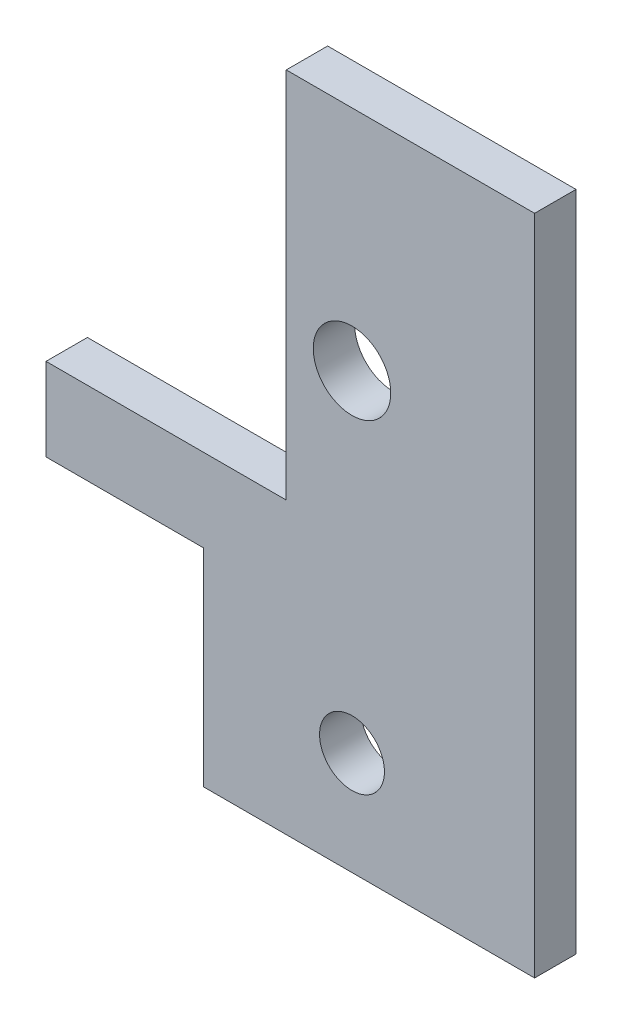
from build123d import *

# Parameters (mm, degrees)
SKETCH1_R           = 2.4892
SKETCH1_R_2         = 2.9718
BOSS_EXTRUDE1_DEPTH = 3.175
SKETCH2_W           = 18.4277
SKETCH2_H           = 6.35
CUT_EXTRUDE1_DEPTH  = 4.175


with BuildPart() as part:
    # Sketch1 → Boss-Extrude1 (new body)
    with BuildSketch(Plane.XY):
        Polygon((37.4777, 9.5377), (0, 9.5377), (0, 3.1877), (18.4277, 3.1877), (18.4277, -19.0373), (0, -19.0373), (0, -25.3873), (12.0777, -25.3873), (12.0777, -41.2623), (37.4777, -41.2623), align=None)
        with Locations((23.471581917, -33.3248)):
            Circle(SKETCH1_R, mode=Mode.SUBTRACT)
        with Locations((23.471581917, -7.9248)):
            Circle(SKETCH1_R_2, mode=Mode.SUBTRACT)
    extrude(amount=BOSS_EXTRUDE1_DEPTH)

    # Sketch2 → Cut-Extrude1 (cut, through all)
    with BuildSketch(Plane(origin=(0, 0, 0), x_dir=(-1, 0, 0), z_dir=(0, 0, -1))):
        with Locations((-9.21385, 6.3627)):
            Rectangle(SKETCH2_W, SKETCH2_H)
    extrude(amount=-CUT_EXTRUDE1_DEPTH, mode=Mode.SUBTRACT)


solid = part.part
